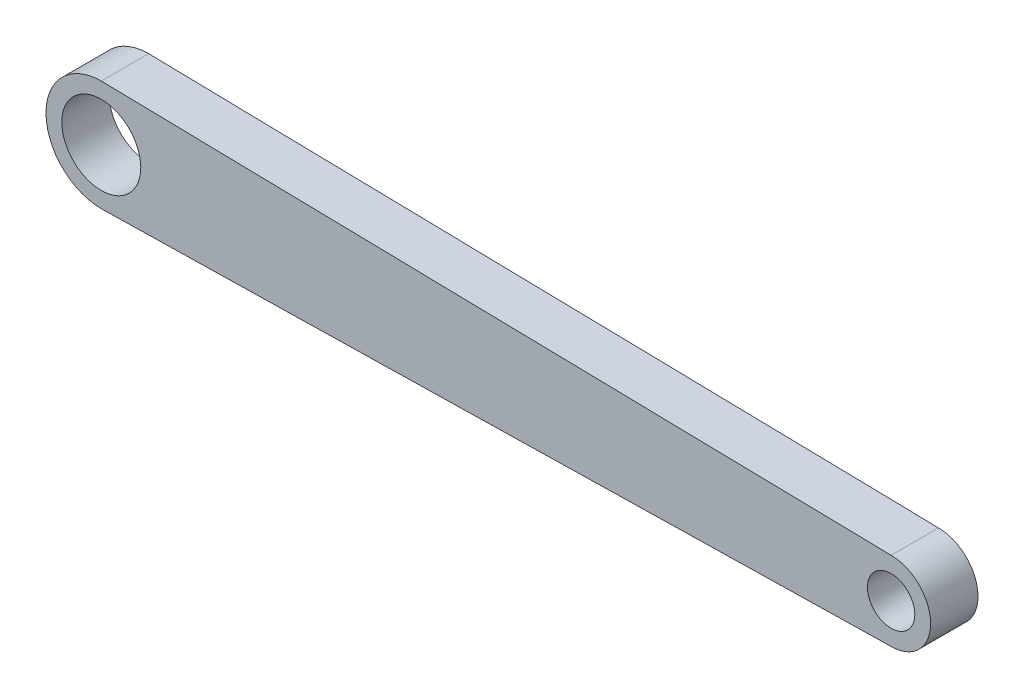
from build123d import *

# Parameters (mm, degrees)
SKETCH1_R           = 2.5
SKETCH1_R_2         = 1.5
BOSS_EXTRUDE1_DEPTH = 3


with BuildPart() as part:
    # Sketch1 → Boss-Extrude1 (new body)
    with BuildSketch(Plane.XY):
        with BuildLine():
            Line((0.139944022, 3.49720112), (0, 3.5))
            ThreePointArc((0, 3.5), (-3.5, 0), (0, -3.5))
            Line((0, -3.5), (0.139944022, -3.49720112))
            Line((0.139944022, -3.49720112), (50, -2.5))
            ThreePointArc((50, -2.5), (52.5, 0), (50, 2.5))
            Line((50, 2.5), (0.139944022, 3.49720112))
        make_face()
        Circle(SKETCH1_R, mode=Mode.SUBTRACT)
        with Locations((50, 0)):
            Circle(SKETCH1_R_2, mode=Mode.SUBTRACT)
    extrude(amount=BOSS_EXTRUDE1_DEPTH)


solid = part.part
